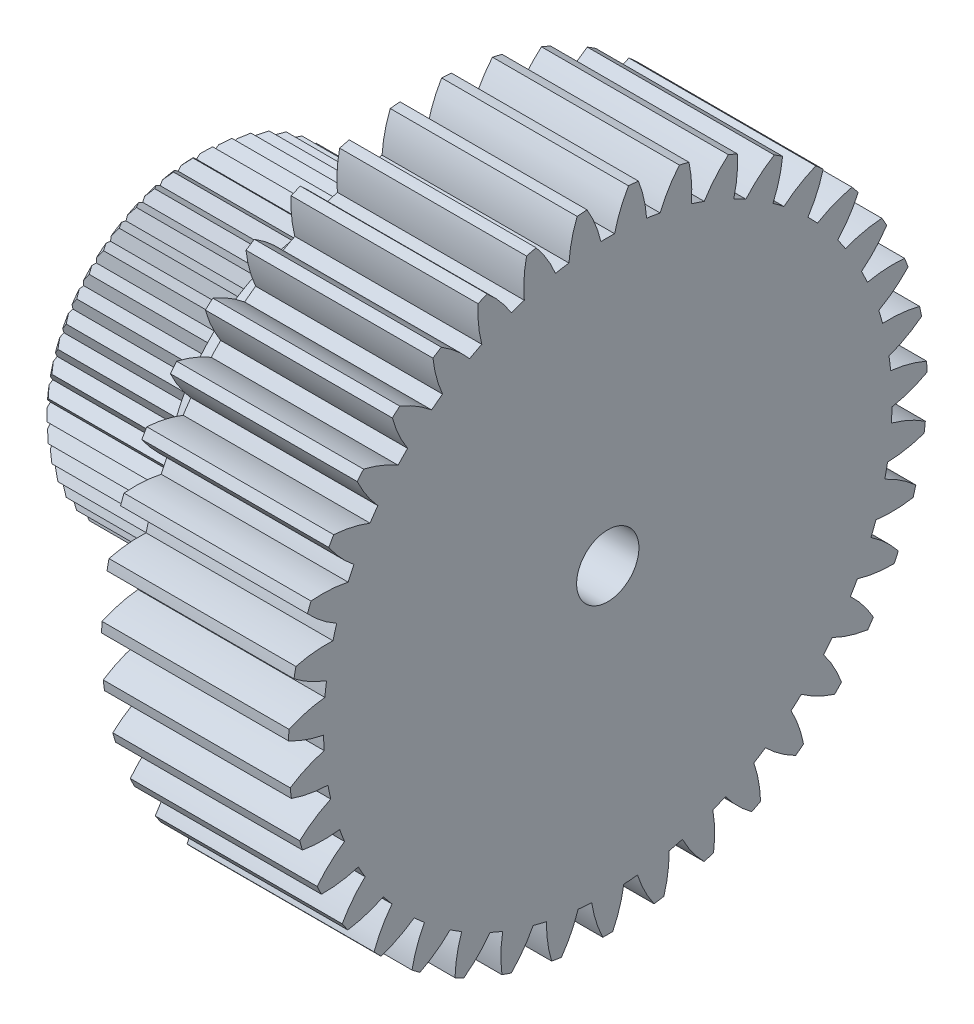
from build123d import *

# Parameters (mm, degrees)
ESQUISSE1_W                       = 3
ESQUISSE1_H                       = 5.125
ENL_V_MAT_EXTRU_1_DEPTH           = 4
ENL_V_MAT_EXTRU_2_DEPTH           = 4
ENL_V_MAT_EXTRU_3_DEPTH           = 4
ENL_V_MAT_EXTRU_4_DEPTH           = 4
ENL_V_MAT_EXTRU_5_DEPTH           = 4
ENL_V_MAT_EXTRU_6_DEPTH           = 4
ENL_V_MAT_EXTRU_7_DEPTH           = 4
ENL_V_MAT_EXTRU_8_DEPTH           = 4
ENL_V_MAT_EXTRU_9_DEPTH           = 4
ENL_V_MAT_EXTRU_10_DEPTH          = 4
ENL_V_MAT_EXTRU_11_DEPTH          = 4
ENL_V_MAT_EXTRU_12_DEPTH          = 4
ENL_V_MAT_EXTRU_13_DEPTH          = 4
ENL_V_MAT_EXTRU_14_DEPTH          = 4
ENL_V_MAT_EXTRU_15_DEPTH          = 4
ENL_V_MAT_EXTRU_16_DEPTH          = 4
ENL_V_MAT_EXTRU_17_DEPTH          = 4
ENL_V_MAT_EXTRU_18_DEPTH          = 4
ENL_V_MAT_EXTRU_19_DEPTH          = 4
ENL_V_MAT_EXTRU_20_DEPTH          = 4
ENL_V_MAT_EXTRU_21_DEPTH          = 4
ENL_V_MAT_EXTRU_22_DEPTH          = 4
ENL_V_MAT_EXTRU_23_DEPTH          = 4
ENL_V_MAT_EXTRU_24_DEPTH          = 4
ENL_V_MAT_EXTRU_25_DEPTH          = 4
ENL_V_MAT_EXTRU_26_DEPTH          = 4
ENL_V_MAT_EXTRU_27_DEPTH          = 4
ENL_V_MAT_EXTRU_28_DEPTH          = 4
ENL_V_MAT_EXTRU_29_DEPTH          = 4
ENL_V_MAT_EXTRU_30_DEPTH          = 4
ENL_V_MAT_EXTRU_31_DEPTH          = 4
ENL_V_MAT_EXTRU_32_DEPTH          = 4
ENL_V_MAT_EXTRU_33_DEPTH          = 4
ENL_V_MAT_EXTRU_34_DEPTH          = 4
ENL_V_MAT_EXTRU_35_DEPTH          = 4
ENL_V_MAT_EXTRU_36_DEPTH          = 4
ENL_V_MAT_EXTRU_37_DEPTH          = 4
ENL_V_MAT_EXTRU_38_DEPTH          = 4
ENL_V_MAT_EXTRU_39_DEPTH          = 4
DIAM_TRE_DU_PER_AGE_7_0_7_1_D     = 7
DIAM_TRE_DU_PER_AGE_7_0_7_1_DEPTH = 1
ESQUISSE43_W                      = 4.0000508
ESQUISSE43_H                      = 2.5
DIAM_TRE_DU_PER_AGE_1_0_1_1_D     = 1
DIAM_TRE_DU_PER_AGE_1_0_1_1_DEPTH = 6.0000508
ESQUISSE46_R                      = 2.5
ESQUISSE46_R_2                    = 0.5
BOSS_EXTRU_1_DEPTH                = 0.6
CHANFREIN1_SIZE                   = 0.1
ESQUISSE47_R                      = 3.148480787
ENL_V_MAT_EXTRU_40_DEPTH          = 2


with BuildPart() as part:
    # Esquisse1 → Révolution1 (revolve)
    with BuildSketch(Plane(origin=(0, 0, 0), x_dir=(-1, 0, 0), z_dir=(0, 0, -1))):
        with Locations((-1.5, 2.5625)):
            Rectangle(ESQUISSE1_W, ESQUISSE1_H)
    revolve(axis=Axis((3, 0, 0), (-1, 0, 0)))

    # Esquisse2 → Enlèv. mat.-Extru.1 (cut, through all)
    with BuildSketch(Plane(origin=(3, 0, 0), x_dir=(0, 0, -1), z_dir=(1, 0, 0))):
        with BuildLine():
            ThreePointArc((1.935434293, 4.745494611), (1.622923468, 4.861249265), (1.303550238, 4.956448504))
            ThreePointArc((1.303550238, 4.956448504), (1.34465145, 4.65976669), (1.339832802, 4.360290164))
            ThreePointArc((1.339832802, 4.360290164), (1.444481054, 4.32674898), (1.548290948, 4.290696609))
            ThreePointArc((1.548290948, 4.290696609), (1.724346921, 4.533005716), (1.935434293, 4.745494611))
        make_face()
    extrude(amount=-ENL_V_MAT_EXTRU_1_DEPTH, mode=Mode.SUBTRACT)

    # Esquisse3 → Enlèv. mat.-Extru.2 (cut, through all)
    with BuildSketch(Plane(origin=(3, 0, 0), x_dir=(0, 0, -1), z_dir=(1, 0, 0))):
        with BuildLine():
            ThreePointArc((2.671601796, 4.373576208), (2.381706257, 4.537962131), (2.081739858, 4.683159635))
            ThreePointArc((2.081739858, 4.683159635), (2.07471771, 4.383726673), (2.021922049, 4.088901256))
            ThreePointArc((2.021922049, 4.088901256), (2.119834749, 4.039007661), (2.216517126, 3.986769881))
            ThreePointArc((2.216517126, 3.986769881), (2.429162334, 4.197699784), (2.671601796, 4.373576208))
        make_face()
    extrude(amount=-ENL_V_MAT_EXTRU_2_DEPTH, mode=Mode.SUBTRACT)

    # Esquisse4 → Enlèv. mat.-Extru.3 (cut, through all)
    with BuildSketch(Plane(origin=(3, 0, 0), x_dir=(0, 0, -1), z_dir=(1, 0, 0))):
        with BuildLine():
            ThreePointArc((3.338576216, 3.888384478), (3.078804104, 4.097144162), (2.806013509, 4.28857939))
            ThreePointArc((2.806013509, 4.28857939), (2.751049871, 3.994150439), (2.651644577, 3.711611952))
            ThreePointArc((2.651644577, 3.711611952), (2.740285838, 3.646658165), (2.827336674, 3.579587907))
            ThreePointArc((2.827336674, 3.579587907), (3.071063719, 3.753675633), (3.338576216, 3.888384478))
        make_face()
    extrude(amount=-ENL_V_MAT_EXTRU_3_DEPTH, mode=Mode.SUBTRACT)

    # Esquisse5 → Enlèv. mat.-Extru.4 (cut, through all)
    with BuildSketch(Plane(origin=(3, 0, 0), x_dir=(0, 0, -1), z_dir=(1, 0, 0))):
        with BuildLine():
            ThreePointArc((3.919083265, 3.302485634), (3.696162543, 3.550212312), (3.457612884, 3.782927193))
            ThreePointArc((3.457612884, 3.782927193), (3.356131286, 3.501127806), (3.212690904, 3.23819385))
            ThreePointArc((3.212690904, 3.23819385), (3.289764964, 3.159862139), (3.364929688, 3.079696486))
            ThreePointArc((3.364929688, 3.079696486), (3.633426167, 3.212433254), (3.919083265, 3.302485634))
        make_face()
    extrude(amount=-ENL_V_MAT_EXTRU_4_DEPTH, mode=Mode.SUBTRACT)

    # Esquisse6 → Enlèv. mat.-Extru.5 (cut, through all)
    with BuildSketch(Plane(origin=(3, 0, 0), x_dir=(0, 0, -1), z_dir=(1, 0, 0))):
        with BuildLine():
            ThreePointArc((4.398088117, 2.631054146), (4.217792313, 2.911331827), (4.019661902, 3.179299168))
            ThreePointArc((4.019661902, 3.179299168), (3.874290663, 2.917427803), (3.690530223, 2.680908227))
            ThreePointArc((3.690530223, 2.680908227), (3.754040904, 2.591227342), (3.81537279, 2.500042544))
            ThreePointArc((3.81537279, 2.500042544), (4.101684785, 2.587990542), (4.398088117, 2.631054146))
        make_face()
    extrude(amount=-ENL_V_MAT_EXTRU_5_DEPTH, mode=Mode.SUBTRACT)

    # Esquisse7 → Enlèv. mat.-Extru.6 (cut, through all)
    with BuildSketch(Plane(origin=(3, 0, 0), x_dir=(0, 0, -1), z_dir=(1, 0, 0))):
        with BuildLine():
            ThreePointArc((4.763184796, 1.891479738), (4.630183477, 2.197049377), (4.477603787, 2.493328964))
            ThreePointArc((4.477603787, 2.493328964), (4.292107947, 2.258167951), (4.072786749, 2.054188489))
            ThreePointArc((4.072786749, 2.054188489), (4.121089157, 1.955481119), (4.166999741, 1.855638814))
            ThreePointArc((4.166999741, 1.855638814), (4.463711922, 1.896520234), (4.763184796, 1.891479738))
        make_face()
    extrude(amount=-ENL_V_MAT_EXTRU_6_DEPTH, mode=Mode.SUBTRACT)

    # Esquisse8 → Enlèv. mat.-Extru.7 (cut, through all)
    with BuildSketch(Plane(origin=(3, 0, 0), x_dir=(0, 0, -1), z_dir=(1, 0, 0))):
        with BuildLine():
            ThreePointArc((5.004917491, 1.102916998), (4.922655322, 1.425864503), (4.819578087, 1.74278285))
            ThreePointArc((4.819578087, 1.74278285), (4.59876189, 1.540422736), (4.349560237, 1.374266349))
            ThreePointArc((4.349560237, 1.374266349), (4.381403366, 1.269088962), (4.410703588, 1.163175012))
            ThreePointArc((4.410703588, 1.163175012), (4.710131265, 1.155931048), (5.004917491, 1.102916998))
        make_face()
    extrude(amount=-ENL_V_MAT_EXTRU_7_DEPTH, mode=Mode.SUBTRACT)

    # Esquisse9 → Enlèv. mat.-Extru.8 (cut, through all)
    with BuildSketch(Plane(origin=(3, 0, 0), x_dir=(0, 0, -1), z_dir=(1, 0, 0))):
        with BuildLine():
            ThreePointArc((5.117025453, 0.285789287), (5.08763298, 0.617750486), (5.036727846, 0.947099576))
            ThreePointArc((5.036727846, 0.947099576), (4.786310315, 0.782781381), (4.513682399, 0.658751432))
            ThreePointArc((4.513682399, 0.658751432), (4.528241529, 0.549828067), (4.540172528, 0.440585589))
            ThreePointArc((4.540172528, 0.440585589), (4.834560682, 0.385403856), (5.117025453, 0.285789287))
        make_face()
    extrude(amount=-ENL_V_MAT_EXTRU_8_DEPTH, mode=Mode.SUBTRACT)

    # Esquisse10 → Enlèv. mat.-Extru.9 (cut, through all)
    with BuildSketch(Plane(origin=(3, 0, 0), x_dir=(0, 0, -1), z_dir=(1, 0, 0))):
        with BuildLine():
            ThreePointArc((5.096605143, -0.538740217), (5.120843616, -0.206362943), (5.123428999, 0.12688692))
            ThreePointArc((5.123428999, 0.12688692), (4.849895818, 0.0048664), (4.560902559, -0.073824801))
            ThreePointArc((4.560902559, -0.073824801), (4.557800615, -0.183673086), (4.552053385, -0.293414769))
            ThreePointArc((4.552053385, -0.293414769), (4.833777517, -0.395105094), (5.096605143, -0.538740217))
        make_face()
    extrude(amount=-ENL_V_MAT_EXTRU_9_DEPTH, mode=Mode.SUBTRACT)

    # Esquisse11 → Enlèv. mat.-Extru.10 (cut, through all)
    with BuildSketch(Plane(origin=(3, 0, 0), x_dir=(0, 0, -1), z_dir=(1, 0, 0))):
        with BuildLine():
            ThreePointArc((4.944185436, -1.349316631), (5.021427092, -1.025131681), (5.077436033, -0.69661204))
            ThreePointArc((5.077436033, -0.69661204), (4.787871566, -0.773174619), (4.489997737, -0.804489011))
            ThreePointArc((4.489997737, -0.804489011), (4.469315059, -0.912417202), (4.446038451, -1.019815839))
            ThreePointArc((4.446038451, -1.019815839), (4.707802054, -1.16538103), (4.944185436, -1.349316631))
        make_face()
    extrude(amount=-ENL_V_MAT_EXTRU_10_DEPTH, mode=Mode.SUBTRACT)

    # Esquisse12 → Enlèv. mat.-Extru.11 (cut, through all)
    with BuildSketch(Plane(origin=(3, 0, 0), x_dir=(0, 0, -1), z_dir=(1, 0, 0))):
        with BuildLine():
            ThreePointArc((4.663713924, -2.124946454), (4.791958244, -1.817350046), (4.89994014, -1.502069115))
            ThreePointArc((4.89994014, -1.502069115), (4.601843956, -1.531190821), (4.302804333, -1.514317378))
            ThreePointArc((4.302804333, -1.514317378), (4.265076591, -1.617530192), (4.224873456, -1.719804214))
            ThreePointArc((4.224873456, -1.719804214), (4.45989699, -1.905474209), (4.663713924, -2.124946454))
        make_face()
    extrude(amount=-ENL_V_MAT_EXTRU_11_DEPTH, mode=Mode.SUBTRACT)

    # Esquisse13 → Enlèv. mat.-Extru.12 (cut, through all)
    with BuildSketch(Plane(origin=(3, 0, 0), x_dir=(0, 0, -1), z_dir=(1, 0, 0))):
        with BuildLine():
            ThreePointArc((4.262454672, -2.845541279), (4.438380194, -2.5625), (4.595538371, -2.268623388))
            ThreePointArc((4.595538371, -2.268623388), (4.296631004, -2.249549986), (4.004170557, -2.18492572))
            ThreePointArc((4.004170557, -2.18492572), (3.950374879, -2.28075), (3.894286457, -2.375250564))
            ThreePointArc((3.894286457, -2.375250564), (4.096482937, -2.596216607), (4.262454672, -2.845541279))
        make_face()
    extrude(amount=-ENL_V_MAT_EXTRU_12_DEPTH, mode=Mode.SUBTRACT)

    # Esquisse14 → Enlèv. mat.-Extru.13 (cut, through all)
    with BuildSketch(Plane(origin=(3, 0, 0), x_dir=(0, 0, -1), z_dir=(1, 0, 0))):
        with BuildLine():
            ThreePointArc((3.750800082, -3.492438081), (3.969850429, -3.24128255), (4.172114573, -2.976421508))
            ThreePointArc((4.172114573, -2.976421508), (3.880137567, -2.909646987), (3.601830867, -2.798945633))
            ThreePointArc((3.601830867, -2.798945633), (3.533360533, -2.884899581), (3.462839485, -2.969179171))
            ThreePointArc((3.462839485, -2.969179171), (3.626972127, -3.219718359), (3.750800082, -3.492438081))
        make_face()
    extrude(amount=-ENL_V_MAT_EXTRU_13_DEPTH, mode=Mode.SUBTRACT)

    # Esquisse15 → Enlèv. mat.-Extru.14 (cut, through all)
    with BuildSketch(Plane(origin=(3, 0, 0), x_dir=(0, 0, -1), z_dir=(1, 0, 0))):
        with BuildLine():
            ThreePointArc((3.14200174, -4.04888257), (3.398503623, -3.836117584), (3.640635198, -3.607131873))
            ThreePointArc((3.640635198, -3.607131873), (3.363150604, -3.49438566), (3.106205649, -3.340474325))
            ThreePointArc((3.106205649, -3.340474325), (3.024834006, -3.414331778), (2.941706789, -3.486207598))
            ThreePointArc((2.941706789, -3.486207598), (3.063524645, -3.759831097), (3.14200174, -4.04888257))
        make_face()
    extrude(amount=-ENL_V_MAT_EXTRU_14_DEPTH, mode=Mode.SUBTRACT)

    # Esquisse16 → Enlèv. mat.-Extru.15 (cut, through all)
    with BuildSketch(Plane(origin=(3, 0, 0), x_dir=(0, 0, -1), z_dir=(1, 0, 0))):
        with BuildLine():
            ThreePointArc((2.451827203, -4.500463128), (2.739137359, -4.331599188), (3.014865285, -4.144419418))
            ThreePointArc((3.014865285, -4.144419418), (2.759059808, -3.988621579), (2.530131336, -3.795486487))
            ThreePointArc((2.530131336, -3.795486487), (2.437965866, -3.855334575), (2.344385433, -3.912945079))
            ThreePointArc((2.344385433, -3.912945079), (2.420733483, -4.202566184), (2.451827203, -4.500463128))
        make_face()
    extrude(amount=-ENL_V_MAT_EXTRU_15_DEPTH, mode=Mode.SUBTRACT)

    # Esquisse17 → Enlèv. mat.-Extru.16 (cut, through all)
    with BuildSketch(Plane(origin=(3, 0, 0), x_dir=(0, 0, -1), z_dir=(1, 0, 0))):
        with BuildLine():
            ThreePointArc((1.69815163, -4.835484054), (2.008828876, -4.714894649), (2.311011944, -4.574368677))
            ThreePointArc((2.311011944, -4.574368677), (2.083510811, -4.379554295), (1.888527951, -4.152197542))
            ThreePointArc((1.888527951, -4.152197542), (1.787955691, -4.196486232), (1.686345725, -4.238339338))
            ThreePointArc((1.686345725, -4.238339338), (1.715246596, -4.536457014), (1.69815163, -4.835484054))
        make_face()
    extrude(amount=-ENL_V_MAT_EXTRU_16_DEPTH, mode=Mode.SUBTRACT)

    # Esquisse18 → Enlèv. mat.-Extru.17 (cut, through all)
    with BuildSketch(Plane(origin=(3, 0, 0), x_dir=(0, 0, -1), z_dir=(1, 0, 0))):
        with BuildLine():
            ThreePointArc((0.900494822, -5.045268484), (1.226492779, -4.976076814), (1.547304608, -4.88584419))
            ThreePointArc((1.547304608, -4.88584419), (1.35399998, -4.657058855), (1.198012684, -4.401368862))
            ThreePointArc((1.198012684, -4.401368862), (1.091638403, -4.4289511), (0.984630549, -4.453962835))
            ThreePointArc((0.984630549, -4.453962835), (0.965335723, -4.75285599), (0.900494822, -5.045268484))
        make_face()
    extrude(amount=-ENL_V_MAT_EXTRU_17_DEPTH, mode=Mode.SUBTRACT)

    # Esquisse19 → Enlèv. mat.-Extru.18 (cut, through all)
    with BuildSketch(Plane(origin=(3, 0, 0), x_dir=(0, 0, -1), z_dir=(1, 0, 0))):
        with BuildLine():
            ThreePointArc((0.079515671, -5.12438311), (0.412391165, -5.108381204), (0.743522895, -5.070778905))
            ThreePointArc((0.743522895, -5.070778905), (0.589421259, -4.813948037), (0.476469518, -4.53654704))
            ThreePointArc((0.476469518, -4.53654704), (0.367048253, -4.546708461), (0.257413959, -4.554231033))
            ThreePointArc((0.257413959, -4.554231033), (0.190423162, -4.846158493), (0.079515671, -5.12438311))
        make_face()
    extrude(amount=-ENL_V_MAT_EXTRU_18_DEPTH, mode=Mode.SUBTRACT)

    # Esquisse20 → Enlèv. mat.-Extru.19 (cut, through all)
    with BuildSketch(Plane(origin=(3, 0, 0), x_dir=(0, 0, -1), z_dir=(1, 0, 0))):
        with BuildLine():
            ThreePointArc((-0.743522895, -5.070778905), (-0.412391165, -5.108381204), (-0.079515671, -5.12438311))
            ThreePointArc((-0.079515671, -5.12438311), (-0.190423162, -4.846158493), (-0.257413959, -4.554231033))
            ThreePointArc((-0.257413959, -4.554231033), (-0.367048253, -4.546708461), (-0.476469518, -4.53654704))
            ThreePointArc((-0.476469518, -4.53654704), (-0.589421259, -4.813948037), (-0.743522895, -5.070778905))
        make_face()
    extrude(amount=-ENL_V_MAT_EXTRU_19_DEPTH, mode=Mode.SUBTRACT)

    # Esquisse21 → Enlèv. mat.-Extru.20 (cut, through all)
    with BuildSketch(Plane(origin=(3, 0, 0), x_dir=(0, 0, -1), z_dir=(1, 0, 0))):
        with BuildLine():
            ThreePointArc((-1.547304608, -4.88584419), (-1.226492779, -4.976076814), (-0.900494822, -5.045268484))
            ThreePointArc((-0.900494822, -5.045268484), (-0.965335723, -4.75285599), (-0.984630549, -4.453962835))
            ThreePointArc((-0.984630549, -4.453962835), (-1.091638403, -4.4289511), (-1.198012684, -4.401368862))
            ThreePointArc((-1.198012684, -4.401368862), (-1.35399998, -4.657058855), (-1.547304608, -4.88584419))
        make_face()
    extrude(amount=-ENL_V_MAT_EXTRU_20_DEPTH, mode=Mode.SUBTRACT)

    # Esquisse22 → Enlèv. mat.-Extru.21 (cut, through all)
    with BuildSketch(Plane(origin=(3, 0, 0), x_dir=(0, 0, -1), z_dir=(1, 0, 0))):
        with BuildLine():
            ThreePointArc((-2.311011944, -4.574368677), (-2.008828876, -4.714894649), (-1.69815163, -4.835484054))
            ThreePointArc((-1.69815163, -4.835484054), (-1.715246596, -4.536457014), (-1.686345725, -4.238339338))
            ThreePointArc((-1.686345725, -4.238339338), (-1.787955691, -4.196486232), (-1.888527951, -4.152197542))
            ThreePointArc((-1.888527951, -4.152197542), (-2.083510811, -4.379554295), (-2.311011944, -4.574368677))
        make_face()
    extrude(amount=-ENL_V_MAT_EXTRU_21_DEPTH, mode=Mode.SUBTRACT)

    # Esquisse23 → Enlèv. mat.-Extru.22 (cut, through all)
    with BuildSketch(Plane(origin=(3, 0, 0), x_dir=(0, 0, -1), z_dir=(1, 0, 0))):
        with BuildLine():
            ThreePointArc((-3.014865285, -4.144419418), (-2.739137359, -4.331599188), (-2.451827203, -4.500463128))
            ThreePointArc((-2.451827203, -4.500463128), (-2.420733483, -4.202566184), (-2.344385433, -3.912945079))
            ThreePointArc((-2.344385433, -3.912945079), (-2.437965866, -3.855334575), (-2.530131336, -3.795486487))
            ThreePointArc((-2.530131336, -3.795486487), (-2.759059808, -3.988621579), (-3.014865285, -4.144419418))
        make_face()
    extrude(amount=-ENL_V_MAT_EXTRU_22_DEPTH, mode=Mode.SUBTRACT)

    # Esquisse24 → Enlèv. mat.-Extru.23 (cut, through all)
    with BuildSketch(Plane(origin=(3, 0, 0), x_dir=(0, 0, -1), z_dir=(1, 0, 0))):
        with BuildLine():
            ThreePointArc((-3.640635198, -3.607131873), (-3.398503623, -3.836117584), (-3.14200174, -4.04888257))
            ThreePointArc((-3.14200174, -4.04888257), (-3.063524645, -3.759831097), (-2.941706789, -3.486207598))
            ThreePointArc((-2.941706789, -3.486207598), (-3.024834006, -3.414331778), (-3.106205649, -3.340474325))
            ThreePointArc((-3.106205649, -3.340474325), (-3.363150604, -3.49438566), (-3.640635198, -3.607131873))
        make_face()
    extrude(amount=-ENL_V_MAT_EXTRU_23_DEPTH, mode=Mode.SUBTRACT)

    # Esquisse25 → Enlèv. mat.-Extru.24 (cut, through all)
    with BuildSketch(Plane(origin=(3, 0, 0), x_dir=(0, 0, -1), z_dir=(1, 0, 0))):
        with BuildLine():
            ThreePointArc((-4.172114573, -2.976421508), (-3.969850429, -3.24128255), (-3.750800082, -3.492438081))
            ThreePointArc((-3.750800082, -3.492438081), (-3.626972127, -3.219718359), (-3.462839485, -2.969179171))
            ThreePointArc((-3.462839485, -2.969179171), (-3.533360533, -2.884899581), (-3.601830867, -2.798945633))
            ThreePointArc((-3.601830867, -2.798945633), (-3.880137567, -2.909646987), (-4.172114573, -2.976421508))
        make_face()
    extrude(amount=-ENL_V_MAT_EXTRU_24_DEPTH, mode=Mode.SUBTRACT)

    # Esquisse26 → Enlèv. mat.-Extru.25 (cut, through all)
    with BuildSketch(Plane(origin=(3, 0, 0), x_dir=(0, 0, -1), z_dir=(1, 0, 0))):
        with BuildLine():
            ThreePointArc((-4.595538371, -2.268623388), (-4.438380194, -2.5625), (-4.262454672, -2.845541279))
            ThreePointArc((-4.262454672, -2.845541279), (-4.096482937, -2.596216607), (-3.894286457, -2.375250564))
            ThreePointArc((-3.894286457, -2.375250564), (-3.950374879, -2.28075), (-4.004170557, -2.18492572))
            ThreePointArc((-4.004170557, -2.18492572), (-4.296631004, -2.249549986), (-4.595538371, -2.268623388))
        make_face()
    extrude(amount=-ENL_V_MAT_EXTRU_25_DEPTH, mode=Mode.SUBTRACT)

    # Esquisse27 → Enlèv. mat.-Extru.26 (cut, through all)
    with BuildSketch(Plane(origin=(3, 0, 0), x_dir=(0, 0, -1), z_dir=(1, 0, 0))):
        with BuildLine():
            ThreePointArc((-4.89994014, -1.502069115), (-4.791958244, -1.817350046), (-4.663713924, -2.124946454))
            ThreePointArc((-4.663713924, -2.124946454), (-4.45989699, -1.905474209), (-4.224873456, -1.719804214))
            ThreePointArc((-4.224873456, -1.719804214), (-4.265076591, -1.617530192), (-4.302804333, -1.514317378))
            ThreePointArc((-4.302804333, -1.514317378), (-4.601843956, -1.531190821), (-4.89994014, -1.502069115))
        make_face()
    extrude(amount=-ENL_V_MAT_EXTRU_26_DEPTH, mode=Mode.SUBTRACT)

    # Esquisse28 → Enlèv. mat.-Extru.27 (cut, through all)
    with BuildSketch(Plane(origin=(3, 0, 0), x_dir=(0, 0, -1), z_dir=(1, 0, 0))):
        with BuildLine():
            ThreePointArc((-5.077436033, -0.69661204), (-5.021427092, -1.025131681), (-4.944185436, -1.349316631))
            ThreePointArc((-4.944185436, -1.349316631), (-4.707802054, -1.16538103), (-4.446038451, -1.019815839))
            ThreePointArc((-4.446038451, -1.019815839), (-4.469315059, -0.912417202), (-4.489997737, -0.804489011))
            ThreePointArc((-4.489997737, -0.804489011), (-4.787871566, -0.773174619), (-5.077436033, -0.69661204))
        make_face()
    extrude(amount=-ENL_V_MAT_EXTRU_27_DEPTH, mode=Mode.SUBTRACT)

    # Esquisse29 → Enlèv. mat.-Extru.28 (cut, through all)
    with BuildSketch(Plane(origin=(3, 0, 0), x_dir=(0, 0, -1), z_dir=(1, 0, 0))):
        with BuildLine():
            ThreePointArc((-5.123428999, 0.12688692), (-5.120843616, -0.206362943), (-5.096605143, -0.538740217))
            ThreePointArc((-5.096605143, -0.538740217), (-4.833777517, -0.395105094), (-4.552053385, -0.293414769))
            ThreePointArc((-4.552053385, -0.293414769), (-4.557800615, -0.183673086), (-4.560902559, -0.073824801))
            ThreePointArc((-4.560902559, -0.073824801), (-4.849895818, 0.0048664), (-5.123428999, 0.12688692))
        make_face()
    extrude(amount=-ENL_V_MAT_EXTRU_28_DEPTH, mode=Mode.SUBTRACT)

    # Esquisse30 → Enlèv. mat.-Extru.29 (cut, through all)
    with BuildSketch(Plane(origin=(3, 0, 0), x_dir=(0, 0, -1), z_dir=(1, 0, 0))):
        with BuildLine():
            ThreePointArc((-5.036727846, 0.947099576), (-5.08763298, 0.617750486), (-5.117025453, 0.285789287))
            ThreePointArc((-5.117025453, 0.285789287), (-4.834560682, 0.385403856), (-4.540172528, 0.440585589))
            ThreePointArc((-4.540172528, 0.440585589), (-4.528241529, 0.549828067), (-4.513682399, 0.658751432))
            ThreePointArc((-4.513682399, 0.658751432), (-4.786310315, 0.782781381), (-5.036727846, 0.947099576))
        make_face()
    extrude(amount=-ENL_V_MAT_EXTRU_29_DEPTH, mode=Mode.SUBTRACT)

    # Esquisse31 → Enlèv. mat.-Extru.30 (cut, through all)
    with BuildSketch(Plane(origin=(3, 0, 0), x_dir=(0, 0, -1), z_dir=(1, 0, 0))):
        with BuildLine():
            ThreePointArc((-4.819578087, 1.74278285), (-4.922655322, 1.425864503), (-5.004917491, 1.102916998))
            ThreePointArc((-5.004917491, 1.102916998), (-4.710131265, 1.155931048), (-4.410703588, 1.163175012))
            ThreePointArc((-4.410703588, 1.163175012), (-4.381403366, 1.269088962), (-4.349560237, 1.374266349))
            ThreePointArc((-4.349560237, 1.374266349), (-4.59876189, 1.540422736), (-4.819578087, 1.74278285))
        make_face()
    extrude(amount=-ENL_V_MAT_EXTRU_30_DEPTH, mode=Mode.SUBTRACT)

    # Esquisse32 → Enlèv. mat.-Extru.31 (cut, through all)
    with BuildSketch(Plane(origin=(3, 0, 0), x_dir=(0, 0, -1), z_dir=(1, 0, 0))):
        with BuildLine():
            ThreePointArc((-4.477603787, 2.493328964), (-4.630183477, 2.197049377), (-4.763184796, 1.891479738))
            ThreePointArc((-4.763184796, 1.891479738), (-4.463711922, 1.896520234), (-4.166999741, 1.855638814))
            ThreePointArc((-4.166999741, 1.855638814), (-4.121089157, 1.955481119), (-4.072786749, 2.054188489))
            ThreePointArc((-4.072786749, 2.054188489), (-4.292107947, 2.258167951), (-4.477603787, 2.493328964))
        make_face()
    extrude(amount=-ENL_V_MAT_EXTRU_31_DEPTH, mode=Mode.SUBTRACT)

    # Esquisse33 → Enlèv. mat.-Extru.32 (cut, through all)
    with BuildSketch(Plane(origin=(3, 0, 0), x_dir=(0, 0, -1), z_dir=(1, 0, 0))):
        with BuildLine():
            ThreePointArc((-4.019661902, 3.179299168), (-4.217792313, 2.911331827), (-4.398088117, 2.631054146))
            ThreePointArc((-4.398088117, 2.631054146), (-4.101684785, 2.587990542), (-3.81537279, 2.500042544))
            ThreePointArc((-3.81537279, 2.500042544), (-3.754040904, 2.591227342), (-3.690530223, 2.680908227))
            ThreePointArc((-3.690530223, 2.680908227), (-3.874290663, 2.917427803), (-4.019661902, 3.179299168))
        make_face()
    extrude(amount=-ENL_V_MAT_EXTRU_32_DEPTH, mode=Mode.SUBTRACT)

    # Esquisse34 → Enlèv. mat.-Extru.33 (cut, through all)
    with BuildSketch(Plane(origin=(3, 0, 0), x_dir=(0, 0, -1), z_dir=(1, 0, 0))):
        with BuildLine():
            ThreePointArc((-3.457612884, 3.782927193), (-3.696162543, 3.550212312), (-3.919083265, 3.302485634))
            ThreePointArc((-3.919083265, 3.302485634), (-3.633426167, 3.212433254), (-3.364929688, 3.079696486))
            ThreePointArc((-3.364929688, 3.079696486), (-3.289764964, 3.159862139), (-3.212690904, 3.23819385))
            ThreePointArc((-3.212690904, 3.23819385), (-3.356131286, 3.501127806), (-3.457612884, 3.782927193))
        make_face()
    extrude(amount=-ENL_V_MAT_EXTRU_33_DEPTH, mode=Mode.SUBTRACT)

    # Esquisse35 → Enlèv. mat.-Extru.34 (cut, through all)
    with BuildSketch(Plane(origin=(3, 0, 0), x_dir=(0, 0, -1), z_dir=(1, 0, 0))):
        with BuildLine():
            ThreePointArc((-2.806013509, 4.28857939), (-3.078804104, 4.097144162), (-3.338576216, 3.888384478))
            ThreePointArc((-3.338576216, 3.888384478), (-3.071063719, 3.753675633), (-2.827336674, 3.579587907))
            ThreePointArc((-2.827336674, 3.579587907), (-2.740285838, 3.646658165), (-2.651644577, 3.711611952))
            ThreePointArc((-2.651644577, 3.711611952), (-2.751049871, 3.994150439), (-2.806013509, 4.28857939))
        make_face()
    extrude(amount=-ENL_V_MAT_EXTRU_34_DEPTH, mode=Mode.SUBTRACT)

    # Esquisse36 → Enlèv. mat.-Extru.35 (cut, through all)
    with BuildSketch(Plane(origin=(3, 0, 0), x_dir=(0, 0, -1), z_dir=(1, 0, 0))):
        with BuildLine():
            ThreePointArc((-2.081739858, 4.683159635), (-2.381706257, 4.537962131), (-2.671601796, 4.373576208))
            ThreePointArc((-2.671601796, 4.373576208), (-2.429162334, 4.197699784), (-2.216517126, 3.986769881))
            ThreePointArc((-2.216517126, 3.986769881), (-2.119834749, 4.039007661), (-2.021922049, 4.088901256))
            ThreePointArc((-2.021922049, 4.088901256), (-2.07471771, 4.383726673), (-2.081739858, 4.683159635))
        make_face()
    extrude(amount=-ENL_V_MAT_EXTRU_35_DEPTH, mode=Mode.SUBTRACT)

    # Esquisse37 → Enlèv. mat.-Extru.36 (cut, through all)
    with BuildSketch(Plane(origin=(3, 0, 0), x_dir=(0, 0, -1), z_dir=(1, 0, 0))):
        with BuildLine():
            ThreePointArc((-1.303550238, 4.956448504), (-1.622923468, 4.861249265), (-1.935434293, 4.745494611))
            ThreePointArc((-1.935434293, 4.745494611), (-1.724346921, 4.533005716), (-1.548290948, 4.290696609))
            ThreePointArc((-1.548290948, 4.290696609), (-1.444481054, 4.32674898), (-1.339832802, 4.360290164))
            ThreePointArc((-1.339832802, 4.360290164), (-1.34465145, 4.65976669), (-1.303550238, 4.956448504))
        make_face()
    extrude(amount=-ENL_V_MAT_EXTRU_36_DEPTH, mode=Mode.SUBTRACT)

    # Esquisse38 → Enlèv. mat.-Extru.37 (cut, through all)
    with BuildSketch(Plane(origin=(3, 0, 0), x_dir=(0, 0, -1), z_dir=(1, 0, 0))):
        with BuildLine():
            ThreePointArc((-0.491599352, 5.101367961), (-0.822107814, 5.058632596), (-1.149140058, 4.994507196))
            ThreePointArc((-1.149140058, 4.994507196), (-0.974871828, 4.75090918), (-0.839964848, 4.483496549))
            ThreePointArc((-0.839964848, 4.483496549), (-0.731716058, 4.502429773), (-0.623042589, 4.518749847))
            ThreePointArc((-0.623042589, 4.518749847), (-0.579759423, 4.815121196), (-0.491599352, 5.101367961))
        make_face()
    extrude(amount=-ENL_V_MAT_EXTRU_37_DEPTH, mode=Mode.SUBTRACT)

    # Esquisse39 → Enlèv. mat.-Extru.38 (cut, through all)
    with BuildSketch(Plane(origin=(3, 0, 0), x_dir=(0, 0, -1), z_dir=(1, 0, 0))):
        with BuildLine():
            ThreePointArc((0.3330837, 5.114164668), (0, 5.125), (-0.3330837, 5.114164668))
            ThreePointArc((-0.3330837, 5.114164668), (-0.200148067, 4.845766593), (-0.1098841, 4.560176283))
            ThreePointArc((-0.1098841, 4.560176283), (0, 4.5615), (0.1098841, 4.560176283))
            ThreePointArc((0.1098841, 4.560176283), (0.200148067, 4.845766593), (0.3330837, 5.114164668))
        make_face()
    extrude(amount=-ENL_V_MAT_EXTRU_38_DEPTH, mode=Mode.SUBTRACT)

    # Esquisse40 → Enlèv. mat.-Extru.39 (cut, through all)
    with BuildSketch(Plane(origin=(3, 0, 0), x_dir=(0, 0, -1), z_dir=(1, 0, 0))):
        with BuildLine():
            ThreePointArc((1.149140058, 4.994507196), (0.822107814, 5.058632596), (0.491599352, 5.101367961))
            ThreePointArc((0.491599352, 5.101367961), (0.579759423, 4.815121196), (0.623042589, 4.518749847))
            ThreePointArc((0.623042589, 4.518749847), (0.731716058, 4.502429773), (0.839964848, 4.483496549))
            ThreePointArc((0.839964848, 4.483496549), (0.974871828, 4.75090918), (1.149140058, 4.994507196))
        make_face()
    extrude(amount=-ENL_V_MAT_EXTRU_39_DEPTH, mode=Mode.SUBTRACT)

    # Diamètre du perçage Ø7.0 (7)1
    with Locations(Plane.ZY):
        with Locations((0, 0)):
            Hole(DIAM_TRE_DU_PER_AGE_7_0_7_1_D / 2, depth=DIAM_TRE_DU_PER_AGE_7_0_7_1_DEPTH)

    # Esquisse43 → Révolution2 (revolve)
    with BuildSketch(Plane.XY):
        with Locations((-1.0000254, 1.25)):
            Rectangle(ESQUISSE43_W, ESQUISSE43_H)
    revolve(axis=Axis((-3.0000508, 0, 0), (1, 0, 0)))

    # Diamètre du perçage Ø1.0 (1)1
    with Locations(Plane(origin=(3, 0, 0), x_dir=(0, 0, -1), z_dir=(1, 0, 0))):
        with Locations((0, 0)):
            Hole(DIAM_TRE_DU_PER_AGE_1_0_1_1_D / 2, depth=DIAM_TRE_DU_PER_AGE_1_0_1_1_DEPTH)

    # Esquisse46 → Boss.-Extru.1 (add)
    with BuildSketch(Plane.ZY.offset(3.0000508)):
        Circle(ESQUISSE46_R)
        Circle(ESQUISSE46_R_2, mode=Mode.SUBTRACT)
    extrude(amount=BOSS_EXTRU_1_DEPTH)

    # Chanfrein1
    chanfrein1_edges = [part.edges().sort_by_distance(p)[0] for p in [
        (-3.6000508, 0, -2.5),
    ]]
    chamfer(chanfrein1_edges, length=CHANFREIN1_SIZE)

    # Esquisse47 → Enlèv. mat.-Extru.40 (cut)
    with BuildSketch(Plane.ZY.offset(3.6000508)):
        Circle(ESQUISSE47_R)
        Polygon((-0.156976299, 2.495066821), (0, 2.35), (0.156976299, 2.495066821), (0.294533099, 2.331469548), (0.468453286, 2.455718127), (0.584421235, 2.276170429), (0.772542486, 2.377641291), (0.865092699, 2.184974742), (1.064448229, 2.262067631), (1.132121134, 2.059320698), (1.339566987, 2.110819814), (1.381295343, 1.901189937), (1.593559974, 1.926283107), (1.608685699, 1.713076274), (1.822421569, 1.711367765), (1.810706121, 1.497946376), (2.022542486, 1.469463131), (1.984170625, 1.259192968), (2.1907667, 1.204384185), (2.126343573, 1.000581335), (2.324441215, 0.920311382), (2.234982813, 0.726189937), (2.421457903, 0.621724718), (2.308375039, 0.440346089), (2.480286753, 0.313333084), (2.345362812, 0.147557721), (2.5, 0), (2.345362812, -0.147557721), (2.480286753, -0.313333084), (2.308375039, -0.440346089), (2.421457903, -0.621724718), (2.234982813, -0.726189937), (2.324441215, -0.920311382), (2.126343573, -1.000581335), (2.1907667, -1.204384185), (1.984170625, -1.259192968), (2.022542486, -1.469463131), (1.810706121, -1.497946376), (1.822421569, -1.711367765), (1.608685699, -1.713076274), (1.593559974, -1.926283107), (1.381295343, -1.901189937), (1.339566987, -2.110819814), (1.132121134, -2.059320698), (1.064448229, -2.262067631), (0.865092699, -2.184974742), (0.772542486, -2.377641291), (0.584421235, -2.276170429), (0.468453286, -2.455718127), (0.294533099, -2.331469548), (0.156976299, -2.495066821), (0, -2.35), (-0.156976299, -2.495066821), (-0.294533099, -2.331469548), (-0.468453286, -2.455718127), (-0.584421235, -2.276170429), (-0.772542486, -2.377641291), (-0.865092699, -2.184974742), (-1.064448229, -2.262067631), (-1.132121134, -2.059320698), (-1.339566987, -2.110819814), (-1.381295343, -1.901189937), (-1.593559974, -1.926283107), (-1.608685699, -1.713076274), (-1.822421569, -1.711367765), (-1.810706121, -1.497946376), (-2.022542486, -1.469463131), (-1.984170625, -1.259192968), (-2.1907667, -1.204384185), (-2.126343573, -1.000581335), (-2.324441215, -0.920311382), (-2.234982813, -0.726189937), (-2.421457903, -0.621724718), (-2.308375039, -0.440346089), (-2.480286753, -0.313333084), (-2.345362812, -0.147557721), (-2.5, 0), (-2.345362812, 0.147557721), (-2.480286753, 0.313333084), (-2.308375039, 0.440346089), (-2.421457903, 0.621724718), (-2.234982813, 0.726189937), (-2.324441215, 0.920311382), (-2.126343573, 1.000581335), (-2.1907667, 1.204384185), (-1.984170625, 1.259192968), (-2.022542486, 1.469463131), (-1.810706121, 1.497946376), (-1.822421569, 1.711367765), (-1.608685699, 1.713076274), (-1.593559974, 1.926283107), (-1.381295343, 1.901189937), (-1.339566987, 2.110819814), (-1.132121134, 2.059320698), (-1.064448229, 2.262067631), (-0.865092699, 2.184974742), (-0.772542486, 2.377641291), (-0.584421235, 2.276170429), (-0.468453286, 2.455718127), (-0.294533099, 2.331469548), align=None, mode=Mode.SUBTRACT)
    extrude(amount=-ENL_V_MAT_EXTRU_40_DEPTH, mode=Mode.SUBTRACT)


solid = part.part
